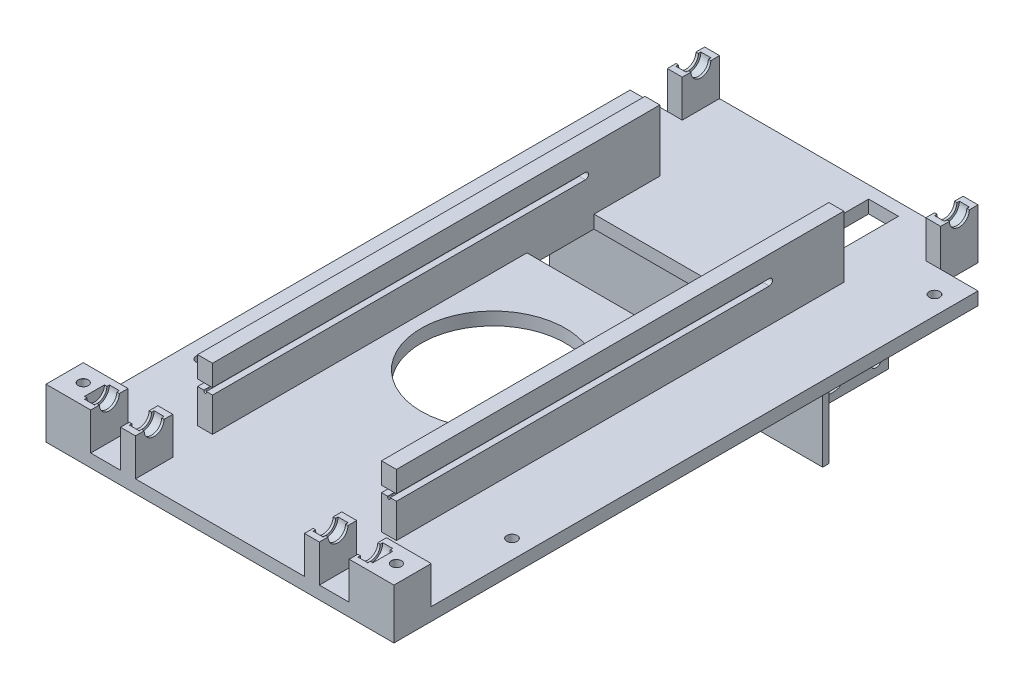
from build123d import *

# Parameters (mm, degrees)
BOSS_EXTRUDE1_DEPTH             = 5.2
SKETCH2_R                       = 29
CUT_EXTRUDE1_DEPTH              = 5.2
SKETCH5_W                       = 6
SKETCH5_H                       = 15
BOSS_EXTRUDE3_DEPTH             = 15
SKETCH8_R                       = 5
CUT_EXTRUDE3_DEPTH              = 2
SKETCH9_R                       = 4
CUT_EXTRUDE4_DEPTH              = 191.628670456
BOSS_EXTRUDE2_DEPTH             = 24.8
CUT_EXTRUDE2_DEPTH              = 183.5
SKETCH15_W                      = 68
SKETCH15_H                      = 30
CUT_EXTRUDE5_DEPTH              = 10
SKETCH16_W                      = 6
SKETCH16_H                      = 45
BOSS_EXTRUDE4_DEPTH             = 40
CUT_EXTRUDE6_DEPTH              = 40
SKETCH19_W                      = 12
SKETCH19_H                      = 40
CUT_EXTRUDE7_DEPTH              = 40
F_4_0MM_DOWEL_HOLE2_D           = 4.2
SKETCH24_W                      = 110
SKETCH24_H                      = 2.5
BOSS_EXTRUDE5_DEPTH             = 40
SKETCH25_W                      = 68
SKETCH25_H                      = 5.2
BOSS_EXTRUDE6_DEPTH             = 3
SKETCH26_W                      = 18
SKETCH26_H                      = 15
SKETCH26_W_2                    = 6
BOSS_EXTRUDE7_DEPTH             = 15
SKETCH27_R                      = 4
CUT_EXTRUDE8_DEPTH              = 58
SKETCH28_R                      = 5
CUT_EXTRUDE9_DEPTH              = 2
LPATTERN1_COUNT                 = 2
LPATTERN1_PITCH                 = 18
LPATTERN2_COUNT                 = 2
LPATTERN2_PITCH                 = 92
LPATTERN2_COPY_1_SKETCH_R       = 5
LPATTERN2_COPY_1_DEPTH          = 2
F_4_0MM_DOWEL_HOLE1_D           = 4
F_4_0MM_DOWEL_HOLE1_DEPTH       = 8
F_4_0MM_DOWEL_HOLE1_CSINK_D     = 4.05
F_4_0MM_DOWEL_HOLE1_CSINK_ANGLE = 90
F_4_0MM_DOWEL_HOLE1_TIP         = 1.201721238


with BuildPart() as part:
    # Sketch1 → Boss-Extrude1 (new body)
    with BuildSketch(Plane(origin=(0, 0, 0), x_dir=(1, 0, 0), z_dir=(0, 1, 0))):
        Polygon((-70, -142.5), (70, -142.5), (70, -117.5), (70, 92.5), (55, 92.5), (55, 107.5), (-55, 107.5), (-55, 92.5), (-70, 92.5), (-70, -127.5), align=None)
    extrude(amount=BOSS_EXTRUDE1_DEPTH)

    # Sketch2 → Cut-Extrude1 (cut)
    with BuildSketch(Plane(origin=(0, 5.2, 0), x_dir=(1, 0, 0), z_dir=(0, 1, 0))):
        with Locations(Location((0, -32.5, 0), (0, 0, 270))):
            Circle(SKETCH2_R)
    extrude(amount=-CUT_EXTRUDE1_DEPTH, mode=Mode.SUBTRACT)

    # Sketch5 → Boss-Extrude3 (add)
    with BuildSketch(Plane(origin=(0, 5.2, 0), x_dir=(1, 0, 0), z_dir=(0, 1, 0))):
        with Locations((52, 100)):
            Rectangle(SKETCH5_W, SKETCH5_H)
        with Locations((-52, 100)):
            Rectangle(SKETCH5_W, SKETCH5_H)
    extrude(amount=BOSS_EXTRUDE3_DEPTH)

    # Sketch8 → Cut-Extrude3 (cut, symmetric)
    with BuildSketch(Plane.ZY.offset(52)):
        with Locations((-100, 20.2)):
            Circle(SKETCH8_R)
    cut_extrude3 = extrude(amount=CUT_EXTRUDE3_DEPTH, both=True, mode=Mode.SUBTRACT)

    # Mirror1: Cut-Extrude3 across plane
    add(cut_extrude3.mirror(Plane.ZY), mode=Mode.SUBTRACT)

    # Sketch9 → Cut-Extrude4 (cut, through all)
    with BuildSketch(Plane.ZY.offset(55)):
        with Locations((-100, 20.2)):
            Circle(SKETCH9_R)
    extrude(amount=-CUT_EXTRUDE4_DEPTH, mode=Mode.SUBTRACT)

    # Sketch3 → Boss-Extrude2 (add)
    with BuildSketch(Plane(origin=(0, 5.2, 0), x_dir=(1, 0, 0), z_dir=(0, 1, 0))):
        Polygon((-34, -32.5), (-34, -111.5), (-40, -111.5), (-40, 68.5), (-34, 68.5), align=None)
        Polygon((40, 68.5), (34, 68.5), (34, -32.5), (34, -111.5), (40, -111.5), align=None)
    extrude(amount=BOSS_EXTRUDE2_DEPTH)

    # Sketch4 → Cut-Extrude2 (cut, through all)
    with BuildSketch(Plane(origin=(40, 0, 0), x_dir=(0, 0, -1), z_dir=(1, 0, 0))):
        with BuildLine():
            Line((-111.5, 21.5), (38.5, 21.5))
            ThreePointArc((38.5, 21.5), (39.8, 20.2), (38.5, 18.9))
            Line((38.5, 18.9), (-111.5, 18.9))
            ThreePointArc((-111.5, 18.9), (-112.8, 20.2), (-111.5, 21.5))
        make_face()
    extrude(amount=-CUT_EXTRUDE2_DEPTH, mode=Mode.SUBTRACT)

    # Cut-Sweep4: sweep along a curve in space
    with BuildLine() as cut_sweep4_path:
        Line((40, 18.9, 111.5), (40, 18.9, -38.5))
    # Sketch10 → Cut-Sweep4 (sweep, cut)
    with BuildSketch(Plane.XY.offset(111.5)):
        with BuildLine():
            Line((36.5, 18.5), (36.5, 18.9))
            Line((36.5, 18.9), (37.5, 18.9))
            Line((37.5, 18.9), (37.5, 18.5))
            ThreePointArc((37.5, 18.5), (37, 18), (36.5, 18.5))
        make_face()
    cut_sweep4 = sweep(path=cut_sweep4_path.line, mode=Mode.SUBTRACT)

    # Mirror2: Cut-Sweep4 across plane
    add(cut_sweep4.mirror(Plane.ZY), mode=Mode.SUBTRACT)

    # Sketch15 → Cut-Extrude5 (cut)
    with BuildSketch(Plane(origin=(0, 5.2, 0), x_dir=(1, 0, 0), z_dir=(0, 1, 0))):
        with Locations((0, 30)):
            Rectangle(SKETCH15_W, SKETCH15_H)
    extrude(amount=-CUT_EXTRUDE5_DEPTH, mode=Mode.SUBTRACT)

    # Sketch16 → Boss-Extrude4 (add)
    with BuildSketch(Plane.XZ):
        with Locations((31, -70)):
            Rectangle(SKETCH16_W, SKETCH16_H)
    extrude(amount=BOSS_EXTRUDE4_DEPTH)

    # Sketch17 → Cut-Extrude6 (cut)
    with BuildSketch(Plane.ZY.offset(-28)):
        with BuildLine():
            Line((-85.4, -5), (-85.4, -35))
            ThreePointArc((-85.4, -35), (-87.5, -37.1), (-89.6, -35))
            Line((-89.6, -35), (-89.6, -5))
            ThreePointArc((-89.6, -5), (-87.5, -2.9), (-85.4, -5))
        make_face()
        with BuildLine():
            Line((-50.4, -5), (-50.4, -35))
            ThreePointArc((-50.4, -35), (-52.5, -37.1), (-54.6, -35))
            Line((-54.6, -35), (-54.6, -5))
            ThreePointArc((-54.6, -5), (-52.5, -2.9), (-50.4, -5))
        make_face()
        with BuildLine():
            Line((-63, -10), (-63, -30))
            ThreePointArc((-63, -30), (-70, -37), (-77, -30))
            Line((-77, -30), (-77, -10))
            ThreePointArc((-77, -10), (-70, -3), (-63, -10))
        make_face()
    extrude(amount=-CUT_EXTRUDE6_DEPTH, mode=Mode.SUBTRACT)

    # Sketch19 → Cut-Extrude7 (cut)
    with BuildSketch(Plane.XZ):
        with Locations((22, -82.5)):
            Rectangle(SKETCH19_W, SKETCH19_H)
    extrude(amount=-CUT_EXTRUDE7_DEPTH, mode=Mode.SUBTRACT)

    # Ø4.0mm Dowel Hole2 (through all)
    with Locations(Plane(origin=(0, 5.2, 0), x_dir=(1, 0, 0), z_dir=(0, 1, 0))):
        with Locations((-62.5, 82.5), (62.5, 82.5), (62.5, -87.5), (-62.5, -87.5)):
            Hole(F_4_0MM_DOWEL_HOLE2_D / 2)

    # Sketch24 → Boss-Extrude5 (add)
    with BuildSketch(Plane.XZ):
        with Locations((0, -46.25)):
            Rectangle(SKETCH24_W, SKETCH24_H)
    extrude(amount=BOSS_EXTRUDE5_DEPTH)

    # Sketch25 → Boss-Extrude6 (add)
    with BuildSketch(Plane.XY.offset(-45)):
        with Locations((0, 2.6)):
            Rectangle(SKETCH25_W, SKETCH25_H)
    extrude(amount=BOSS_EXTRUDE6_DEPTH)

    # Sketch26 → Boss-Extrude7 (add)
    with BuildSketch(Plane(origin=(0, 5.2, 0), x_dir=(1, 0, 0), z_dir=(0, 1, 0))):
        with Locations((-61, -135)):
            Rectangle(SKETCH26_W, SKETCH26_H)
        with Locations((61, -135)):
            Rectangle(SKETCH26_W, SKETCH26_H)
        with Locations((-37, -135)):
            Rectangle(SKETCH26_W_2, SKETCH26_H)
        with Locations((37, -135)):
            Rectangle(SKETCH26_W_2, SKETCH26_H)
    extrude(amount=BOSS_EXTRUDE7_DEPTH)

    # Sketch27 → Cut-Extrude8 (cut, symmetric)
    with BuildSketch(Plane.ZY):
        with Locations((135, 20.2)):
            Circle(SKETCH27_R)
    extrude(amount=CUT_EXTRUDE8_DEPTH, both=True, mode=Mode.SUBTRACT)

    # Sketch28 → Cut-Extrude9 (cut, symmetric)
    with BuildSketch(Plane(origin=(-55, 0, 0), x_dir=(0, 0, -1), z_dir=(1, 0, 0))):
        with Locations((-135, 20.2)):
            Circle(SKETCH28_R)
    cut_extrude9 = extrude(amount=CUT_EXTRUDE9_DEPTH, both=True, mode=Mode.SUBTRACT)

    # LPattern1: Cut-Extrude9 ×2
    with Locations(*[(i * LPATTERN1_PITCH, 0, 0) for i in range(1, LPATTERN1_COUNT)]):
        add(cut_extrude9, mode=Mode.SUBTRACT)

    # LPattern2: Cut-Extrude9 ×2
    with Locations(*[(i * LPATTERN2_PITCH, 0, 0) for i in range(1, LPATTERN2_COUNT)]):
        add(cut_extrude9, mode=Mode.SUBTRACT)

    # LPattern2 copy 1 sketch → LPattern2 copy 1 (cut, symmetric)
    with BuildSketch(Plane(origin=(55, 0, 0), x_dir=(0, 0, -1), z_dir=(1, 0, 0))):
        with Locations((-135, 20.2)):
            Circle(LPATTERN2_COPY_1_SKETCH_R)
    extrude(amount=LPATTERN2_COPY_1_DEPTH, both=True, mode=Mode.SUBTRACT)

    # Ø4.0mm Dowel Hole1
    with Locations(Plane(origin=(0, 20.2, 0), x_dir=(1, 0, 0), z_dir=(0, 1, 0))):
        with Locations((-63, -134.5), (63, -134.5)):
            CounterSinkHole(F_4_0MM_DOWEL_HOLE1_D / 2, F_4_0MM_DOWEL_HOLE1_CSINK_D / 2, depth=F_4_0MM_DOWEL_HOLE1_DEPTH, counter_sink_angle=F_4_0MM_DOWEL_HOLE1_CSINK_ANGLE)
            with Locations((0, 0, -(F_4_0MM_DOWEL_HOLE1_DEPTH + F_4_0MM_DOWEL_HOLE1_TIP / 2))):  # 118° drill point
                Cone(0, F_4_0MM_DOWEL_HOLE1_D / 2, F_4_0MM_DOWEL_HOLE1_TIP, mode=Mode.SUBTRACT)


solid = part.part
